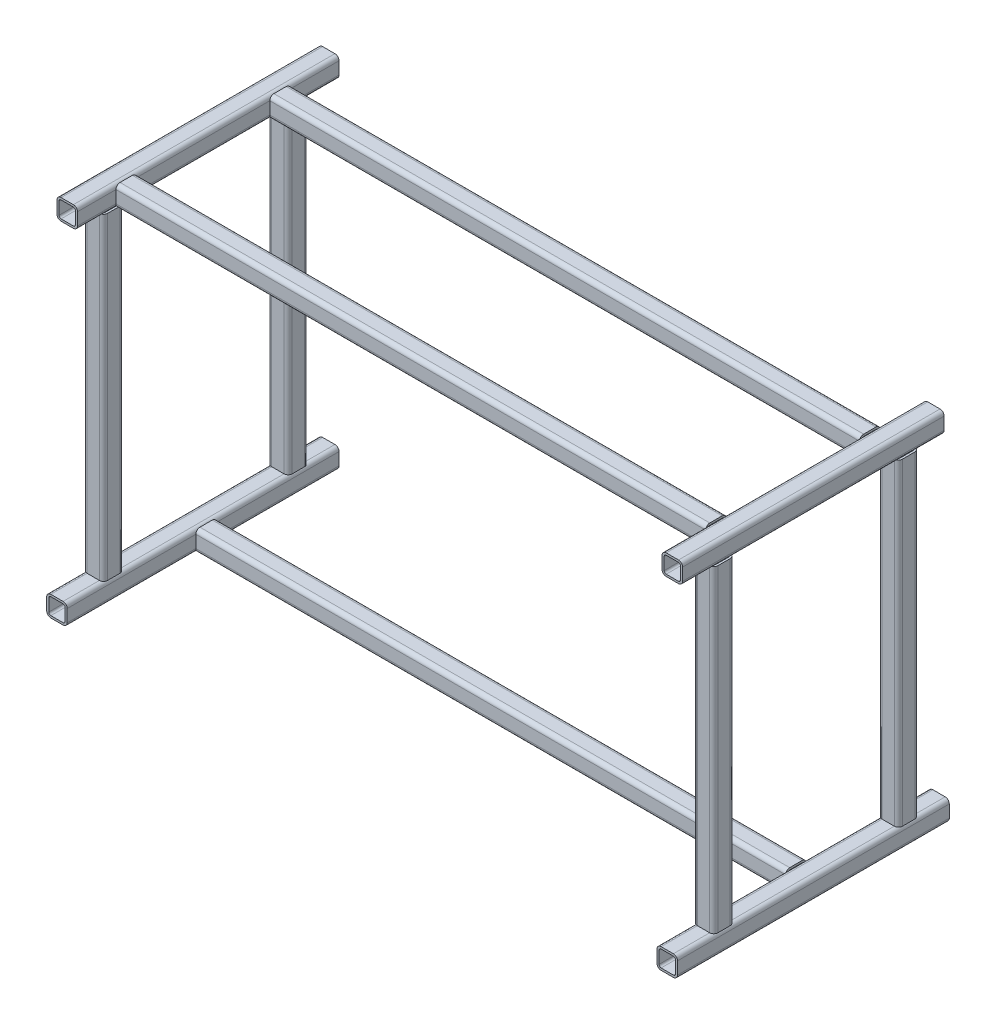
from build123d import *

# Parameters (mm, degrees)
TUBO_CUADRADO_40_X_40_X_4_1_DEPTH   = 530
TUBO_CUADRADO_40_X_40_X_4_1_2_DEPTH = 530
TUBO_CUADRADO_40_X_40_X_4_1_3_DEPTH = 1192
TUBO_CUADRADO_40_X_40_X_4_2_DEPTH   = 620
TUBO_CUADRADO_40_X_40_X_4_2_2_DEPTH = 620
TUBO_CUADRADO_40_X_40_X_4_3_DEPTH   = 620
TUBO_CUADRADO_40_X_40_X_4_3_2_DEPTH = 620
TUBO_CUADRADO_40_X_40_X_4_5_DEPTH   = 510
TUBO_CUADRADO_40_X_40_X_4_5_2_DEPTH = 510
TUBO_CUADRADO_40_X_40_X_4_5_3_DEPTH = 1192
TUBO_CUADRADO_40_X_40_X_4_5_4_DEPTH = 1192


with BuildPart() as part:
    # Sketch1 → Tubo cuadrado 40 X 40 X 4(1) (new body)
    with BuildSketch(Plane(origin=(-595, 0, -259.213973799), x_dir=(1, 0, 0), z_dir=(0, 0, 1))):
        with BuildLine():
            Line((-12, -20), (12, -20))
            ThreePointArc((12, -20), (17.656854249, -17.656854249), (20, -12))
            Line((20, -12), (20, 12))
            ThreePointArc((20, 12), (17.656854249, 17.656854249), (12, 20))
            Line((12, 20), (-12, 20))
            ThreePointArc((-12, 20), (-17.656854249, 17.656854249), (-20, 12))
            Line((-20, 12), (-20, -12))
            ThreePointArc((-20, -12), (-17.656854249, -17.656854249), (-12, -20))
        make_face()
        with BuildLine():
            Line((-12, -16), (12, -16))
            ThreePointArc((12, -16), (14.828427125, -14.828427125), (16, -12))
            Line((16, -12), (16, 12))
            ThreePointArc((16, 12), (14.828427125, 14.828427125), (12, 16))
            Line((12, 16), (-12, 16))
            ThreePointArc((-12, 16), (-14.828427125, 14.828427125), (-16, 12))
            Line((-16, 12), (-16, -12))
            ThreePointArc((-16, -12), (-14.828427125, -14.828427125), (-12, -16))
        make_face(mode=Mode.SUBTRACT)
    extrude(amount=TUBO_CUADRADO_40_X_40_X_4_1_DEPTH)


with BuildPart() as body_2:
    # Sketch1 on segment 2 (carried to segment 2) → Tubo cuadrado 40 X 40 X 4_1 2 (new body)
    with BuildSketch(Plane(origin=(595, 0, -259.213973799), x_dir=(1, 0, 0), z_dir=(0, 0, 1))):
        with BuildLine():
            Line((-12, -20), (12, -20))
            ThreePointArc((12, -20), (17.656854249, -17.656854249), (20, -12))
            Line((20, -12), (20, 12))
            ThreePointArc((20, 12), (17.656854249, 17.656854249), (12, 20))
            Line((12, 20), (-12, 20))
            ThreePointArc((-12, 20), (-17.656854249, 17.656854249), (-20, 12))
            Line((-20, 12), (-20, -12))
            ThreePointArc((-20, -12), (-17.656854249, -17.656854249), (-12, -20))
        make_face()
        with BuildLine():
            Line((-12, -16), (12, -16))
            ThreePointArc((12, -16), (14.828427125, -14.828427125), (16, -12))
            Line((16, -12), (16, 12))
            ThreePointArc((16, 12), (14.828427125, 14.828427125), (12, 16))
            Line((12, 16), (-12, 16))
            ThreePointArc((-12, 16), (-14.828427125, 14.828427125), (-16, 12))
            Line((-16, 12), (-16, -12))
            ThreePointArc((-16, -12), (-14.828427125, -14.828427125), (-12, -16))
        make_face(mode=Mode.SUBTRACT)
    extrude(amount=TUBO_CUADRADO_40_X_40_X_4_1_2_DEPTH)


with BuildPart() as body_3:
    # Sketch1 on segment 3 (carried to segment 3) → Tubo cuadrado 40 X 40 X 4_1 3 (new body)
    with BuildSketch(Plane(origin=(-596, 0, 0), x_dir=(0, 0, -1), z_dir=(1, 0, 0))):
        with BuildLine():
            Line((-12, -20), (12, -20))
            ThreePointArc((12, -20), (17.656854249, -17.656854249), (20, -12))
            Line((20, -12), (20, 12))
            ThreePointArc((20, 12), (17.656854249, 17.656854249), (12, 20))
            Line((12, 20), (-12, 20))
            ThreePointArc((-12, 20), (-17.656854249, 17.656854249), (-20, 12))
            Line((-20, 12), (-20, -12))
            ThreePointArc((-20, -12), (-17.656854249, -17.656854249), (-12, -20))
        make_face()
        with BuildLine():
            Line((-12, -16), (12, -16))
            ThreePointArc((12, -16), (14.828427125, -14.828427125), (16, -12))
            Line((16, -12), (16, 12))
            ThreePointArc((16, 12), (14.828427125, 14.828427125), (12, 16))
            Line((12, 16), (-12, 16))
            ThreePointArc((-12, 16), (-14.828427125, 14.828427125), (-16, 12))
            Line((-16, 12), (-16, -12))
            ThreePointArc((-16, -12), (-14.828427125, -14.828427125), (-12, -16))
        make_face(mode=Mode.SUBTRACT)
    extrude(amount=TUBO_CUADRADO_40_X_40_X_4_1_3_DEPTH)

    # Tubo cuadrado 40 X 40 X 4_1 3 end butt 1
    split(bisect_by=Plane.YZ.offset(-575), keep=Keep.TOP)

    # Tubo cuadrado 40 X 40 X 4_1 3 end butt 2
    split(bisect_by=Plane(origin=(575, 0, 0), x_dir=(0, -1, 0), z_dir=(-1, 0, 0)), keep=Keep.TOP)


with BuildPart() as body_4:
    # Sketch11 → Tubo cuadrado 40 X 40 X 4(2) (new body)
    with BuildSketch(Plane(origin=(595, 20, 180), x_dir=(0, 0, 1), z_dir=(0, 1, 0))):
        with BuildLine():
            Line((-12, -20), (12, -20))
            ThreePointArc((12, -20), (17.656854249, -17.656854249), (20, -12))
            Line((20, -12), (20, 12))
            ThreePointArc((20, 12), (17.656854249, 17.656854249), (12, 20))
            Line((12, 20), (-12, 20))
            ThreePointArc((-12, 20), (-17.656854249, 17.656854249), (-20, 12))
            Line((-20, 12), (-20, -12))
            ThreePointArc((-20, -12), (-17.656854249, -17.656854249), (-12, -20))
        make_face()
        with BuildLine():
            Line((-12, -16), (12, -16))
            ThreePointArc((12, -16), (14.828427125, -14.828427125), (16, -12))
            Line((16, -12), (16, 12))
            ThreePointArc((16, 12), (14.828427125, 14.828427125), (12, 16))
            Line((12, 16), (-12, 16))
            ThreePointArc((-12, 16), (-14.828427125, 14.828427125), (-16, 12))
            Line((-16, 12), (-16, -12))
            ThreePointArc((-16, -12), (-14.828427125, -14.828427125), (-12, -16))
        make_face(mode=Mode.SUBTRACT)
    extrude(amount=TUBO_CUADRADO_40_X_40_X_4_2_DEPTH)


with BuildPart() as body_5:
    # Sketch11 on segment 2 (carried to segment 2) → Tubo cuadrado 40 X 40 X 4_2 2 (new body)
    with BuildSketch(Plane(origin=(595, 20, -180), x_dir=(0, 0, 1), z_dir=(0, 1, 0))):
        with BuildLine():
            Line((-12, -20), (12, -20))
            ThreePointArc((12, -20), (17.656854249, -17.656854249), (20, -12))
            Line((20, -12), (20, 12))
            ThreePointArc((20, 12), (17.656854249, 17.656854249), (12, 20))
            Line((12, 20), (-12, 20))
            ThreePointArc((-12, 20), (-17.656854249, 17.656854249), (-20, 12))
            Line((-20, 12), (-20, -12))
            ThreePointArc((-20, -12), (-17.656854249, -17.656854249), (-12, -20))
        make_face()
        with BuildLine():
            Line((-12, -16), (12, -16))
            ThreePointArc((12, -16), (14.828427125, -14.828427125), (16, -12))
            Line((16, -12), (16, 12))
            ThreePointArc((16, 12), (14.828427125, 14.828427125), (12, 16))
            Line((12, 16), (-12, 16))
            ThreePointArc((-12, 16), (-14.828427125, 14.828427125), (-16, 12))
            Line((-16, 12), (-16, -12))
            ThreePointArc((-16, -12), (-14.828427125, -14.828427125), (-12, -16))
        make_face(mode=Mode.SUBTRACT)
    extrude(amount=TUBO_CUADRADO_40_X_40_X_4_2_2_DEPTH)


with BuildPart() as body_6:
    # Sketch12 → Tubo cuadrado 40 X 40 X 4(3) (new body)
    with BuildSketch(Plane(origin=(-595, 20, 180), x_dir=(0, 0, 1), z_dir=(0, 1, 0))):
        with BuildLine():
            Line((-12, -20), (12, -20))
            ThreePointArc((12, -20), (17.656854249, -17.656854249), (20, -12))
            Line((20, -12), (20, 12))
            ThreePointArc((20, 12), (17.656854249, 17.656854249), (12, 20))
            Line((12, 20), (-12, 20))
            ThreePointArc((-12, 20), (-17.656854249, 17.656854249), (-20, 12))
            Line((-20, 12), (-20, -12))
            ThreePointArc((-20, -12), (-17.656854249, -17.656854249), (-12, -20))
        make_face()
        with BuildLine():
            Line((-12, -16), (12, -16))
            ThreePointArc((12, -16), (14.828427125, -14.828427125), (16, -12))
            Line((16, -12), (16, 12))
            ThreePointArc((16, 12), (14.828427125, 14.828427125), (12, 16))
            Line((12, 16), (-12, 16))
            ThreePointArc((-12, 16), (-14.828427125, 14.828427125), (-16, 12))
            Line((-16, 12), (-16, -12))
            ThreePointArc((-16, -12), (-14.828427125, -14.828427125), (-12, -16))
        make_face(mode=Mode.SUBTRACT)
    extrude(amount=TUBO_CUADRADO_40_X_40_X_4_3_DEPTH)


with BuildPart() as body_7:
    # Sketch12 on segment 2 (carried to segment 2) → Tubo cuadrado 40 X 40 X 4_3 2 (new body)
    with BuildSketch(Plane(origin=(-595, 20, -180), x_dir=(0, 0, 1), z_dir=(0, 1, 0))):
        with BuildLine():
            Line((-12, -20), (12, -20))
            ThreePointArc((12, -20), (17.656854249, -17.656854249), (20, -12))
            Line((20, -12), (20, 12))
            ThreePointArc((20, 12), (17.656854249, 17.656854249), (12, 20))
            Line((12, 20), (-12, 20))
            ThreePointArc((-12, 20), (-17.656854249, 17.656854249), (-20, 12))
            Line((-20, 12), (-20, -12))
            ThreePointArc((-20, -12), (-17.656854249, -17.656854249), (-12, -20))
        make_face()
        with BuildLine():
            Line((-12, -16), (12, -16))
            ThreePointArc((12, -16), (14.828427125, -14.828427125), (16, -12))
            Line((16, -12), (16, 12))
            ThreePointArc((16, 12), (14.828427125, 14.828427125), (12, 16))
            Line((12, 16), (-12, 16))
            ThreePointArc((-12, 16), (-14.828427125, 14.828427125), (-16, 12))
            Line((-16, 12), (-16, -12))
            ThreePointArc((-16, -12), (-14.828427125, -14.828427125), (-12, -16))
        make_face(mode=Mode.SUBTRACT)
    extrude(amount=TUBO_CUADRADO_40_X_40_X_4_3_2_DEPTH)


with BuildPart() as body_8:
    # Sketch14 → Tubo cuadrado 40 X 40 X 4(5) (new body)
    with BuildSketch(Plane(origin=(595, 660, 260.786026201), x_dir=(-1, 0, 0), z_dir=(0, 0, -1))):
        with BuildLine():
            Line((-12, -20), (12, -20))
            ThreePointArc((12, -20), (17.656854249, -17.656854249), (20, -12))
            Line((20, -12), (20, 12))
            ThreePointArc((20, 12), (17.656854249, 17.656854249), (12, 20))
            Line((12, 20), (-12, 20))
            ThreePointArc((-12, 20), (-17.656854249, 17.656854249), (-20, 12))
            Line((-20, 12), (-20, -12))
            ThreePointArc((-20, -12), (-17.656854249, -17.656854249), (-12, -20))
        make_face()
        with BuildLine():
            Line((-12, -16), (12, -16))
            ThreePointArc((12, -16), (14.828427125, -14.828427125), (16, -12))
            Line((16, -12), (16, 12))
            ThreePointArc((16, 12), (14.828427125, 14.828427125), (12, 16))
            Line((12, 16), (-12, 16))
            ThreePointArc((-12, 16), (-14.828427125, 14.828427125), (-16, 12))
            Line((-16, 12), (-16, -12))
            ThreePointArc((-16, -12), (-14.828427125, -14.828427125), (-12, -16))
        make_face(mode=Mode.SUBTRACT)
    extrude(amount=TUBO_CUADRADO_40_X_40_X_4_5_DEPTH)


with BuildPart() as body_9:
    # Sketch14 on segment 2 (carried to segment 2) → Tubo cuadrado 40 X 40 X 4_5 2 (new body)
    with BuildSketch(Plane(origin=(-595, 660, 250.786026201), x_dir=(-1, 0, 0), z_dir=(0, 0, -1))):
        with BuildLine():
            Line((-12, -20), (12, -20))
            ThreePointArc((12, -20), (17.656854249, -17.656854249), (20, -12))
            Line((20, -12), (20, 12))
            ThreePointArc((20, 12), (17.656854249, 17.656854249), (12, 20))
            Line((12, 20), (-12, 20))
            ThreePointArc((-12, 20), (-17.656854249, 17.656854249), (-20, 12))
            Line((-20, 12), (-20, -12))
            ThreePointArc((-20, -12), (-17.656854249, -17.656854249), (-12, -20))
        make_face()
        with BuildLine():
            Line((-12, -16), (12, -16))
            ThreePointArc((12, -16), (14.828427125, -14.828427125), (16, -12))
            Line((16, -12), (16, 12))
            ThreePointArc((16, 12), (14.828427125, 14.828427125), (12, 16))
            Line((12, 16), (-12, 16))
            ThreePointArc((-12, 16), (-14.828427125, 14.828427125), (-16, 12))
            Line((-16, 12), (-16, -12))
            ThreePointArc((-16, -12), (-14.828427125, -14.828427125), (-12, -16))
        make_face(mode=Mode.SUBTRACT)
    extrude(amount=TUBO_CUADRADO_40_X_40_X_4_5_2_DEPTH)


with BuildPart() as body_10:
    # Sketch14 on segment 3 (carried to segment 3) → Tubo cuadrado 40 X 40 X 4_5 3 (new body)
    with BuildSketch(Plane(origin=(596, 660, -144.213973799), x_dir=(0, 0, 1), z_dir=(-1, 0, 0))):
        with BuildLine():
            Line((-12, -20), (12, -20))
            ThreePointArc((12, -20), (17.656854249, -17.656854249), (20, -12))
            Line((20, -12), (20, 12))
            ThreePointArc((20, 12), (17.656854249, 17.656854249), (12, 20))
            Line((12, 20), (-12, 20))
            ThreePointArc((-12, 20), (-17.656854249, 17.656854249), (-20, 12))
            Line((-20, 12), (-20, -12))
            ThreePointArc((-20, -12), (-17.656854249, -17.656854249), (-12, -20))
        make_face()
        with BuildLine():
            Line((-12, -16), (12, -16))
            ThreePointArc((12, -16), (14.828427125, -14.828427125), (16, -12))
            Line((16, -12), (16, 12))
            ThreePointArc((16, 12), (14.828427125, 14.828427125), (12, 16))
            Line((12, 16), (-12, 16))
            ThreePointArc((-12, 16), (-14.828427125, 14.828427125), (-16, 12))
            Line((-16, 12), (-16, -12))
            ThreePointArc((-16, -12), (-14.828427125, -14.828427125), (-12, -16))
        make_face(mode=Mode.SUBTRACT)
    extrude(amount=TUBO_CUADRADO_40_X_40_X_4_5_3_DEPTH)

    # Tubo cuadrado 40 X 40 X 4_5 3 end butt 1
    split(bisect_by=Plane(origin=(575, 660, -144.213973799), x_dir=(0, -1, 0), z_dir=(-1, 0, 0)), keep=Keep.TOP)

    # Tubo cuadrado 40 X 40 X 4_5 3 end butt 2
    split(bisect_by=Plane(origin=(-575, 660, -144.213973799), x_dir=(0, 1, 0), z_dir=(1, 0, 0)), keep=Keep.TOP)


with BuildPart() as body_11:
    # Sketch14 on segment 4 (carried to segment 4) → Tubo cuadrado 40 X 40 X 4_5 4 (new body)
    with BuildSketch(Plane(origin=(596, 660, 155.786026201), x_dir=(0, 0, 1), z_dir=(-1, 0, 0))):
        with BuildLine():
            Line((-12, -20), (12, -20))
            ThreePointArc((12, -20), (17.656854249, -17.656854249), (20, -12))
            Line((20, -12), (20, 12))
            ThreePointArc((20, 12), (17.656854249, 17.656854249), (12, 20))
            Line((12, 20), (-12, 20))
            ThreePointArc((-12, 20), (-17.656854249, 17.656854249), (-20, 12))
            Line((-20, 12), (-20, -12))
            ThreePointArc((-20, -12), (-17.656854249, -17.656854249), (-12, -20))
        make_face()
        with BuildLine():
            Line((-12, -16), (12, -16))
            ThreePointArc((12, -16), (14.828427125, -14.828427125), (16, -12))
            Line((16, -12), (16, 12))
            ThreePointArc((16, 12), (14.828427125, 14.828427125), (12, 16))
            Line((12, 16), (-12, 16))
            ThreePointArc((-12, 16), (-14.828427125, 14.828427125), (-16, 12))
            Line((-16, 12), (-16, -12))
            ThreePointArc((-16, -12), (-14.828427125, -14.828427125), (-12, -16))
        make_face(mode=Mode.SUBTRACT)
    extrude(amount=TUBO_CUADRADO_40_X_40_X_4_5_4_DEPTH)

    # Tubo cuadrado 40 X 40 X 4_5 4 end butt 1
    split(bisect_by=Plane(origin=(575, 660, 155.786026201), x_dir=(0, -1, 0), z_dir=(-1, 0, 0)), keep=Keep.TOP)

    # Tubo cuadrado 40 X 40 X 4_5 4 end butt 2
    split(bisect_by=Plane(origin=(-575, 660, 155.786026201), x_dir=(0, 1, 0), z_dir=(1, 0, 0)), keep=Keep.TOP)


solid = Compound([part.part, body_2.part, body_3.part, body_4.part, body_5.part, body_6.part, body_7.part, body_8.part, body_9.part, body_10.part, body_11.part])
